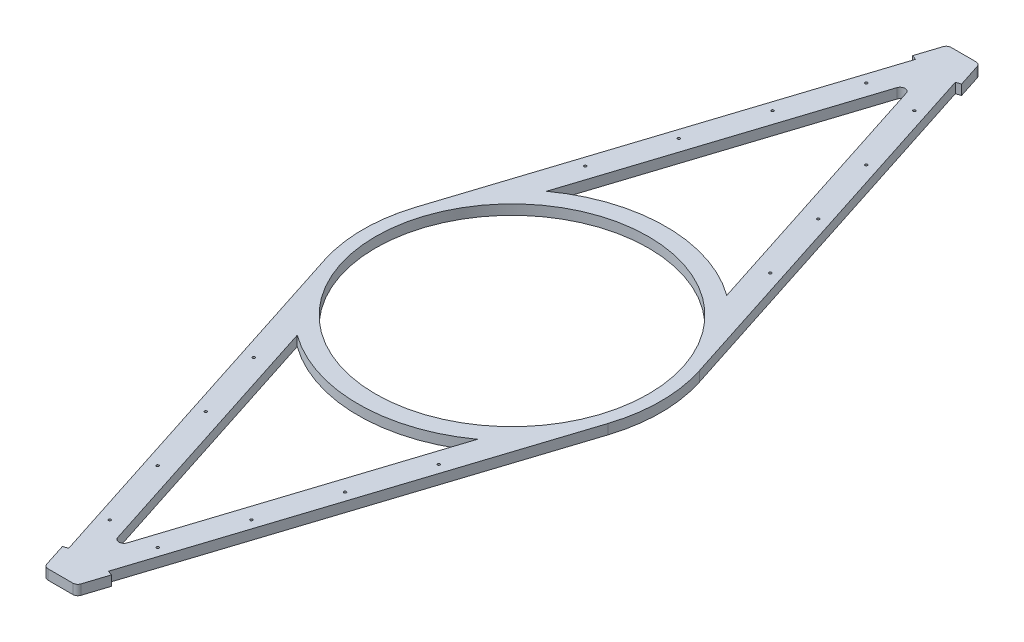
from build123d import *

# Parameters (mm, degrees)
SKETCH2_R           = 2.5
SKETCH2_R_2         = 275
BOSS_EXTRUDE1_DEPTH = 20
CUT_EXTRUDE1_DEPTH  = 21


with BuildPart() as part:
    # Sketch2 → Boss-Extrude1 (new body)
    with BuildSketch(Plane(origin=(0, 0, 0), x_dir=(1, 0, 0), z_dir=(0, 1, 0))):
        with BuildLine():
            Line((-34.517430478, 903.068960265), (-295.040344804, 95.1377682))
            ThreePointArc((-295.040344804, 95.1377682), (-310, 0), (-295.040344804, -95.1377682))
            Line((-295.040344804, -95.1377682), (-34.517430478, -903.068960265))
            ThreePointArc((-34.517430478, -903.068960265), (-30.886866626, -908.083613135), (-25, -910))
            Line((-25, -910), (25, -910))
            ThreePointArc((25, -910), (30.886866626, -908.083613135), (34.517430478, -903.068960265))
            Line((34.517430478, -903.068960265), (295.040344804, -95.1377682))
            ThreePointArc((295.040344804, -95.1377682), (310, 0), (295.040344804, 95.1377682))
            Line((295.040344804, 95.1377682), (34.517430478, 903.068960265))
            ThreePointArc((34.517430478, 903.068960265), (30.886866626, 908.083613135), (25, 910))
            Line((25, 910), (-25, 910))
            ThreePointArc((-25, 910), (-30.886866626, 908.083613135), (-34.517430478, 903.068960265))
        make_face()
        with Locations((-48.373467006, -762.345774842)):
            Circle(SKETCH2_R, mode=Mode.SUBTRACT)
        with Locations((-94.407870974, -619.584317679)):
            Circle(SKETCH2_R, mode=Mode.SUBTRACT)
        with Locations((-140.442274942, -476.822860516)):
            Circle(SKETCH2_R, mode=Mode.SUBTRACT)
        with BuildLine():
            ThreePointArc((-181.680791071, -251.181388952), (0, -310), (181.680791071, -251.181388952))
            Line((181.680791071, -251.181388952), (9.517430478, -785.092770658))
            ThreePointArc((9.517430478, -785.092770658), (0, -792.023810393), (-9.517430478, -785.092770658))
            Line((-9.517430478, -785.092770658), (-181.680791071, -251.181388952))
        make_face(mode=Mode.SUBTRACT)
        with Locations((-186.476678909, -334.061403353)):
            Circle(SKETCH2_R, mode=Mode.SUBTRACT)
        with Locations((48.373467006, -762.345774842)):
            Circle(SKETCH2_R, mode=Mode.SUBTRACT)
        with Locations((94.407870974, -619.584317679)):
            Circle(SKETCH2_R, mode=Mode.SUBTRACT)
        with Locations((140.442274942, -476.822860516)):
            Circle(SKETCH2_R, mode=Mode.SUBTRACT)
        with Locations((186.476678909, -334.061403353)):
            Circle(SKETCH2_R, mode=Mode.SUBTRACT)
        with Locations((-186.476678909, 334.061403353)):
            Circle(SKETCH2_R, mode=Mode.SUBTRACT)
        with Locations((-140.442274942, 476.822860516)):
            Circle(SKETCH2_R, mode=Mode.SUBTRACT)
        with Locations((-94.407870974, 619.584317679)):
            Circle(SKETCH2_R, mode=Mode.SUBTRACT)
        with BuildLine():
            ThreePointArc((181.680791071, 251.181388952), (0, 310), (-181.680791071, 251.181388952))
            Line((-181.680791071, 251.181388952), (-9.517430478, 785.092770658))
            ThreePointArc((-9.517430478, 785.092770658), (0, 792.023810393), (9.517430478, 785.092770658))
            Line((9.517430478, 785.092770658), (181.680791071, 251.181388952))
        make_face(mode=Mode.SUBTRACT)
        with Locations((-48.373467006, 762.345774842)):
            Circle(SKETCH2_R, mode=Mode.SUBTRACT)
        Circle(SKETCH2_R_2, mode=Mode.SUBTRACT)
        with Locations((186.476678909, 334.061403353)):
            Circle(SKETCH2_R, mode=Mode.SUBTRACT)
        with Locations((140.442274942, 476.822860516)):
            Circle(SKETCH2_R, mode=Mode.SUBTRACT)
        with Locations((94.407870974, 619.584317679)):
            Circle(SKETCH2_R, mode=Mode.SUBTRACT)
        with Locations((48.373467006, 762.345774842)):
            Circle(SKETCH2_R, mode=Mode.SUBTRACT)
    extrude(amount=BOSS_EXTRUDE1_DEPTH)

    # Sketch3 → Cut-Extrude1 (cut, through all)
    with BuildSketch(Plane(origin=(0, 20, 0), x_dir=(1, 0, 0), z_dir=(0, 1, 0))):
        with BuildLine():
            Line((-295.040344804, -95.1377682), (-49.523523643, -856.532206403))
            Line((-49.523523643, -856.532206403), (-40.006093165, -853.463246139))
            Line((-40.006093165, -853.463246139), (-285.522914326, -92.068807935))
            ThreePointArc((-285.522914326, -92.068807935), (-300, 0), (-285.522914326, 92.068807935))
            Line((-285.522914326, 92.068807935), (-40.006093165, 853.463246139))
            Line((-40.006093165, 853.463246139), (-49.523523643, 856.532206403))
            Line((-49.523523643, 856.532206403), (-295.040344804, 95.1377682))
            ThreePointArc((-295.040344804, 95.1377682), (-310, 0), (-295.040344804, -95.1377682))
        make_face()
        with BuildLine():
            Line((295.040344804, 95.1377682), (49.523523643, 856.532206403))
            Line((49.523523643, 856.532206403), (40.006093165, 853.463246139))
            Line((40.006093165, 853.463246139), (285.522914326, 92.068807935))
            ThreePointArc((285.522914326, 92.068807935), (300, 0), (285.522914326, -92.068807935))
            Line((285.522914326, -92.068807935), (40.006093165, -853.463246139))
            Line((40.006093165, -853.463246139), (49.523523643, -856.532206403))
            Line((49.523523643, -856.532206403), (295.040344804, -95.1377682))
            ThreePointArc((295.040344804, -95.1377682), (310, 0), (295.040344804, 95.1377682))
        make_face()
    extrude(amount=-CUT_EXTRUDE1_DEPTH, mode=Mode.SUBTRACT)


solid = part.part
